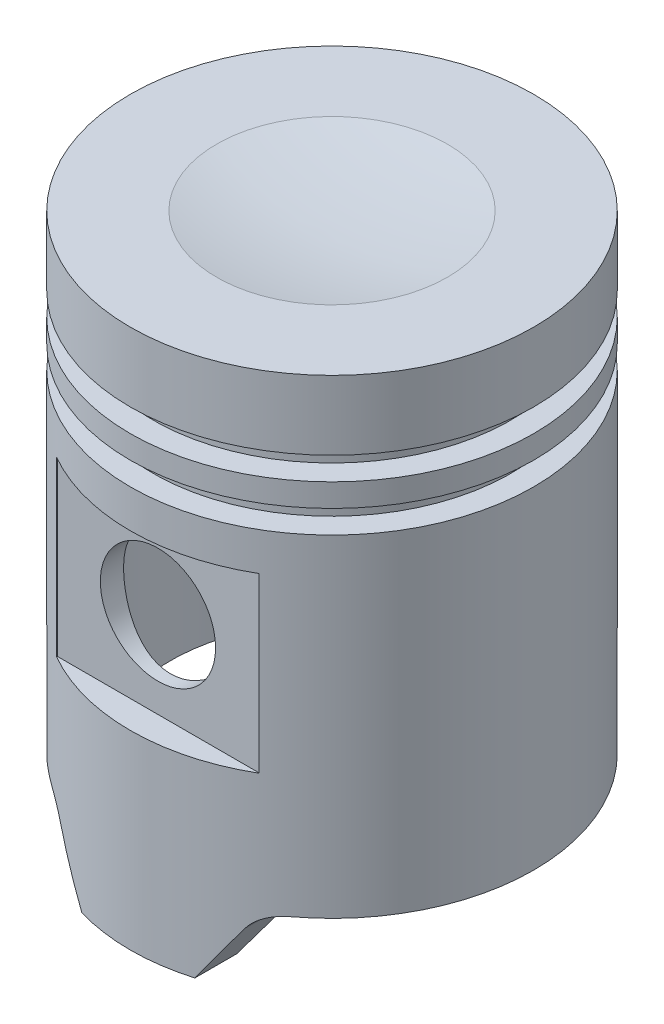
from build123d import *

# Parameters (mm, degrees)
SKETCH2_R               = 17.78
CUT_EXTRUDE1_DEPTH      = 51.816
SKETCH3_R               = 6.35
CUT_EXTRUDE2_DEPTH      = 23.225
CUT_EXTRUDE2_DEPTH_BACK = 23.225
CUT_EXTRUDE3_START      = 19.177
SKETCH4_W               = 22.225
SKETCH4_H               = 19.05
CUT_EXTRUDE3_DEPTH      = 4.0480001
CUT_EXTRUDE4_DEPTH      = 23.225


with BuildPart() as part:
    # Sketch1 → Revolve1 (revolve)
    with BuildSketch(Plane.XY):
        with BuildLine():
            Line((0, 0), (0, 58.166))
            ThreePointArc((0, 58.166), (6.387986381, 58.484288237), (12.712693656, 59.436))
            Line((12.712693656, 59.436), (22.225, 59.436))
            Line((22.225, 59.436), (22.225, 51.816))
            Line((22.225, 51.816), (19.685, 51.816))
            Line((19.685, 51.816), (19.685, 49.276))
            Line((19.685, 49.276), (22.225, 49.276))
            Line((22.225, 49.276), (22.225, 46.736))
            Line((22.225, 46.736), (19.685, 46.736))
            Line((19.685, 46.736), (19.685, 44.196))
            Line((19.685, 44.196), (22.225, 44.196))
            Line((22.225, 44.196), (22.225, 0))
            Line((22.225, 0), (0, 0))
        make_face()
    revolve(axis=Axis((0, 0, 0), (0, 1, 0)))

    # Sketch2 → Cut-Extrude1 (cut)
    with BuildSketch(Plane.XZ):
        Circle(SKETCH2_R)
    extrude(amount=-CUT_EXTRUDE1_DEPTH, mode=Mode.SUBTRACT)

    # Sketch3 → Cut-Extrude2 (cut, two sides)
    with BuildSketch(Plane.XY) as cut_extrude2_sk:
        with Locations((0, 30.48)):
            Circle(SKETCH3_R)
    extrude(amount=CUT_EXTRUDE2_DEPTH, mode=Mode.SUBTRACT)
    extrude(cut_extrude2_sk.sketch, amount=-CUT_EXTRUDE2_DEPTH_BACK, mode=Mode.SUBTRACT)

    # Sketch4 → Cut-Extrude3 (cut, through all)
    with BuildSketch(Plane.XY.offset(CUT_EXTRUDE3_START)):
        with Locations((0.0635, 30.48)):
            Rectangle(SKETCH4_W, SKETCH4_H)
    cut_extrude3 = extrude(amount=CUT_EXTRUDE3_DEPTH, mode=Mode.SUBTRACT)

    # Mirror1: Cut-Extrude3 across plane
    add(cut_extrude3.mirror(Plane.XY), mode=Mode.SUBTRACT)

    # Sketch5 → Cut-Extrude4 (cut, symmetric)
    with BuildSketch(Plane.XY):
        with BuildLine():
            Line((22.225, 0), (22.225, 7.62))
            Line((22.225, 7.62), (13.343533586, 7.62))
            ThreePointArc((13.343533586, 7.62), (11.546046061, 7.169336035), (10.173788381, 5.923957269))
            Line((10.173788381, 5.923957269), (6.223, 0))
            Line((6.223, 0), (22.225, 0))
        make_face()
    cut_extrude4 = extrude(amount=CUT_EXTRUDE4_DEPTH, both=True, mode=Mode.SUBTRACT)

    # Mirror2: Cut-Extrude4 across plane
    add(cut_extrude4.mirror(Plane(origin=(0, 0, 0), x_dir=(0, 0, 1), z_dir=(1, 0, 0))), mode=Mode.SUBTRACT)


solid = part.part
